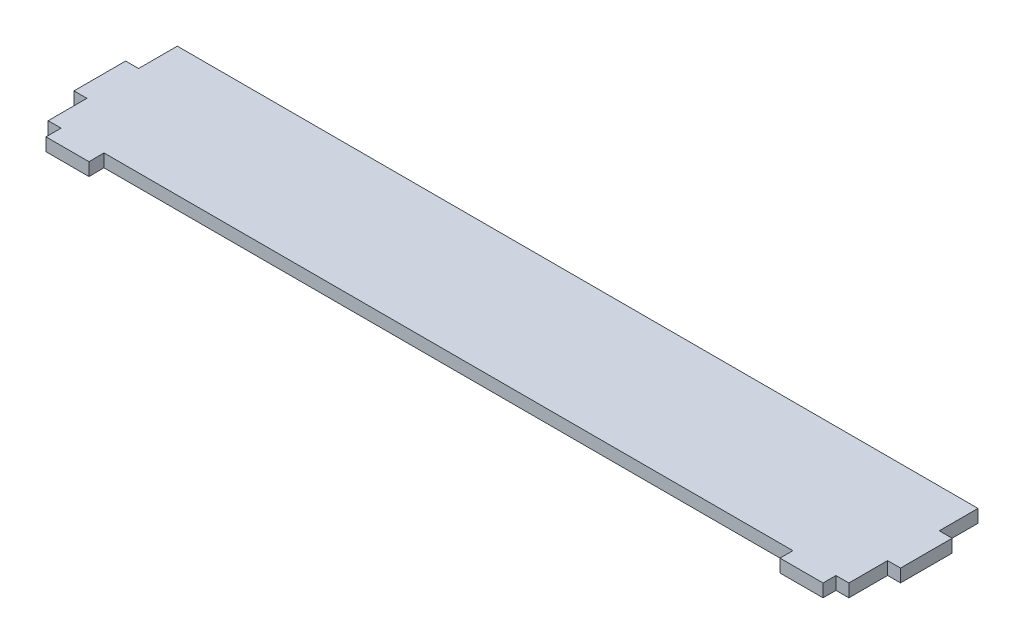
from build123d import *

# Parameters (mm, degrees)
EXTRUDE_1_DEPTH = 3


with BuildPart() as part:
    # 草图4 → 凸台-拉伸1 (new body)
    with BuildSketch(Plane(origin=(0, 0, 0), x_dir=(1, 0, 0), z_dir=(0, 1, 0))):
        Polygon((180, 30), (0, 30), (-3, 30), (-3, 21), (-6, 21), (-6, 9), (-3, 9), (-3, 0), (0, 0), (0, -3.504796537), (10, -3.504796537), (9.95, 0), (10, 0), (170, 0), (170, -3), (180, -3), (180, 0), (183, 0), (183, 9), (186, 9), (186, 21), (183, 21), (183, 30), align=None)
    extrude(amount=EXTRUDE_1_DEPTH)


solid = part.part
